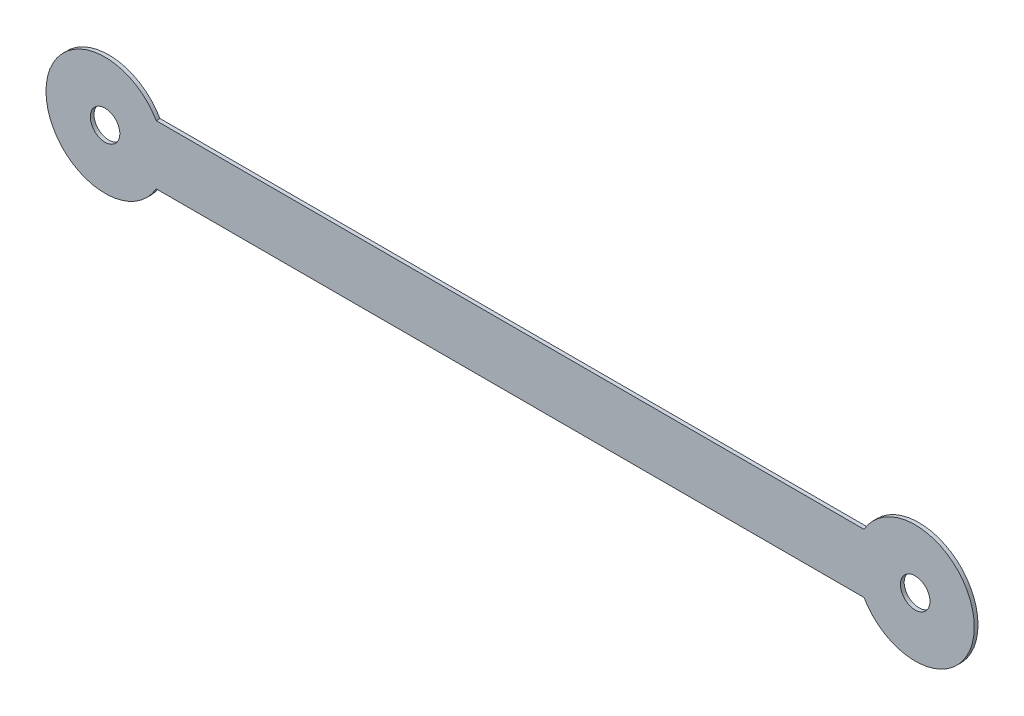
from build123d import *

# Parameters (mm, degrees)
SKETCH1_R           = 1
BOSS_EXTRUDE1_DEPTH = 0.254
CUT_EXTRUDE1_DEPTH  = 1.254


with BuildPart() as part:
    # Sketch1 → Boss-Extrude1 (new body)
    with BuildSketch(Plane.XY):
        with BuildLine():
            Line((0, 4), (54.864, 4))
            ThreePointArc((54.864, 4), (58.864, 0), (54.864, -4))
            Line((54.864, -4), (0, -4))
            ThreePointArc((0, -4), (-4, 0), (0, 4))
        make_face()
        Circle(SKETCH1_R, mode=Mode.SUBTRACT)
        with Locations((54.864, 0)):
            Circle(SKETCH1_R, mode=Mode.SUBTRACT)
    extrude(amount=BOSS_EXTRUDE1_DEPTH)

    # Sketch2 → Cut-Extrude1 (cut, through all)
    with BuildSketch(Plane(origin=(0, 0, 0), x_dir=(-1, 0, 0), z_dir=(0, 0, -1))):
        with BuildLine():
            Line((-51.399898385, 2), (-3.464101615, 2))
            ThreePointArc((-3.464101615, 2), (-2, 3.464101615), (0, 4))
            Line((0, 4), (-54.864, 4))
            ThreePointArc((-54.864, 4), (-52.864, 3.464101615), (-51.399898385, 2))
        make_face()
        with BuildLine():
            Line((-51.399898385, -2), (-3.464101615, -2))
            ThreePointArc((-3.464101615, -2), (-2, -3.464101615), (0, -4))
            Line((0, -4), (-54.864, -4))
            ThreePointArc((-54.864, -4), (-52.864, -3.464101615), (-51.399898385, -2))
        make_face()
    extrude(amount=-CUT_EXTRUDE1_DEPTH, mode=Mode.SUBTRACT)


solid = part.part
